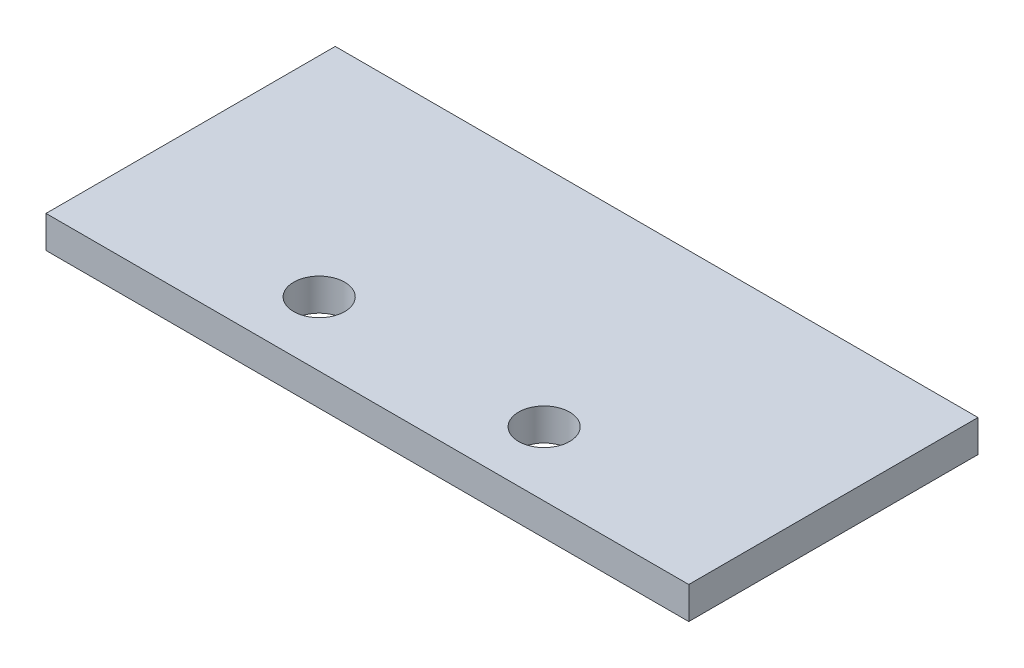
from build123d import *

# Parameters (mm, degrees)
SKETCH1_W           = 127
SKETCH1_H           = 57.15
BOSS_EXTRUDE1_DEPTH = 6.35
SKETCH2_R           = 5.0419
CUT_EXTRUDE1_DEPTH  = 7.35


with BuildPart() as part:
    # Sketch1 → Boss-Extrude1 (new body)
    with BuildSketch(Plane(origin=(0, 0, 0), x_dir=(1, 0, 0), z_dir=(0, 1, 0))):
        with Locations((63.5, 28.575)):
            Rectangle(SKETCH1_W, SKETCH1_H)
    extrude(amount=BOSS_EXTRUDE1_DEPTH)

    # Sketch2 → Cut-Extrude1 (cut, through all)
    with BuildSketch(Plane(origin=(0, 6.35, 0), x_dir=(1, 0, 0), z_dir=(0, 1, 0))):
        with Locations((41.275, 12.7)):
            Circle(SKETCH2_R)
        with Locations((85.725, 12.7)):
            Circle(SKETCH2_R)
    extrude(amount=-CUT_EXTRUDE1_DEPTH, mode=Mode.SUBTRACT)


solid = part.part
